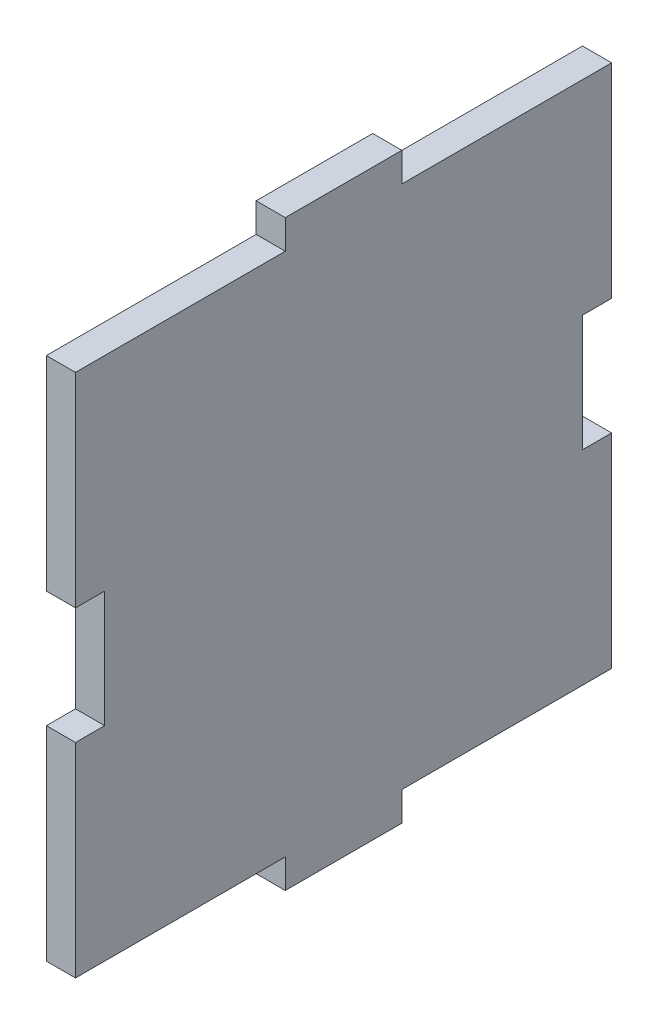
from build123d import *

# Parameters (mm, degrees)
BOSS_EXTRUDE1_DEPTH = 3.175


with BuildPart() as part:
    # Sketch1 → Boss-Extrude1 (new body)
    with BuildSketch(Plane(origin=(0, 0, 0), x_dir=(0, 0, -1), z_dir=(1, 0, 0))):
        Polygon((-29.21, 28.575), (-6.35, 28.575), (-6.35, 31.75), (6.35, 31.75), (6.35, 28.575), (29.21, 28.575), (29.21, 6.35), (26.035, 6.35), (26.035, -6.35), (29.21, -6.35), (29.21, -28.575), (6.35, -28.575), (6.35, -31.75), (-6.35, -31.75), (-6.35, -28.575), (-29.21, -28.575), (-29.21, -6.35), (-26.035, -6.35), (-26.035, 6.35), (-29.21, 6.35), align=None)
    extrude(amount=BOSS_EXTRUDE1_DEPTH)


solid = part.part
